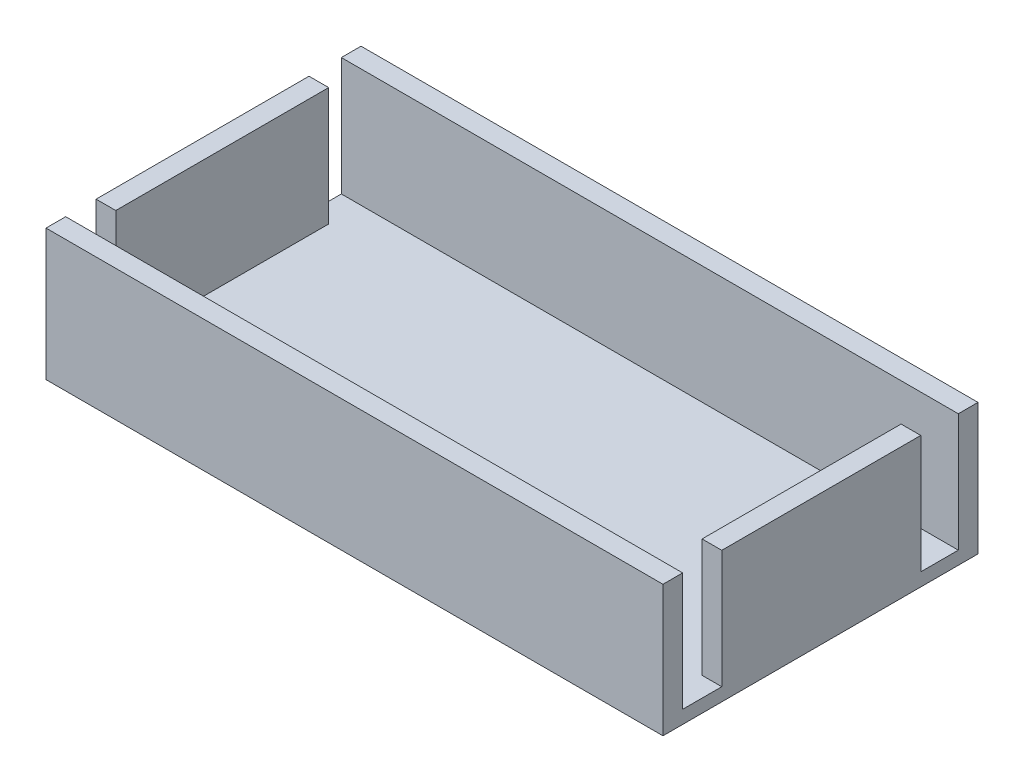
from build123d import *

# Parameters (mm, degrees)
SKETCH1_W           = 47
SKETCH1_H           = 24
SKETCH1_W_2         = 44
SKETCH1_H_2         = 21
BOSS_EXTRUDE1_DEPTH = 1
SKETCH1_3_W         = 47
SKETCH1_3_H         = 24
SKETCH1_3_W_2       = 44
SKETCH1_3_H_2       = 21
BOSS_EXTRUDE2_DEPTH = 10
SKETCH2_W           = 1.5
SKETCH2_H           = 2.861016429
SKETCH2_H_2         = 2.980642968
SKETCH2_H_3         = 2.463825615
SKETCH2_H_4         = 2.315157892
CUT_EXTRUDE1_DEPTH  = 9


with BuildPart() as part:
    # Sketch1 → Boss-Extrude1 (new body)
    with BuildSketch(Plane(origin=(0, 0, 0), x_dir=(1, 0, 0), z_dir=(0, 1, 0))):
        Rectangle(SKETCH1_W, SKETCH1_H)
        Rectangle(SKETCH1_W_2, SKETCH1_H_2, mode=Mode.SUBTRACT)
        Rectangle(SKETCH1_W_2, SKETCH1_H_2)
    extrude(amount=BOSS_EXTRUDE1_DEPTH)

    # Sketch1_3 → Boss-Extrude2 (add)
    with BuildSketch(Plane(origin=(0, 0, 0), x_dir=(1, 0, 0), z_dir=(0, 1, 0))):
        Rectangle(SKETCH1_3_W, SKETCH1_3_H)
        Rectangle(SKETCH1_3_W_2, SKETCH1_3_H_2, mode=Mode.SUBTRACT)
    extrude(amount=BOSS_EXTRUDE2_DEPTH)

    # Sketch2 → Cut-Extrude1 (cut)
    with BuildSketch(Plane(origin=(0, 10, 0), x_dir=(1, 0, 0), z_dir=(0, 1, 0))):
        with Locations((22.75, 9.069491786)):
            Rectangle(SKETCH2_W, SKETCH2_H)
        with Locations((22.75, -9.009678516)):
            Rectangle(SKETCH2_W, SKETCH2_H_2)
        with Locations((-22.75, 9.268087193)):
            Rectangle(SKETCH2_W, SKETCH2_H_3)
        with Locations((-22.75, -9.342421054)):
            Rectangle(SKETCH2_W, SKETCH2_H_4)
    extrude(amount=-CUT_EXTRUDE1_DEPTH, mode=Mode.SUBTRACT)


solid = part.part
